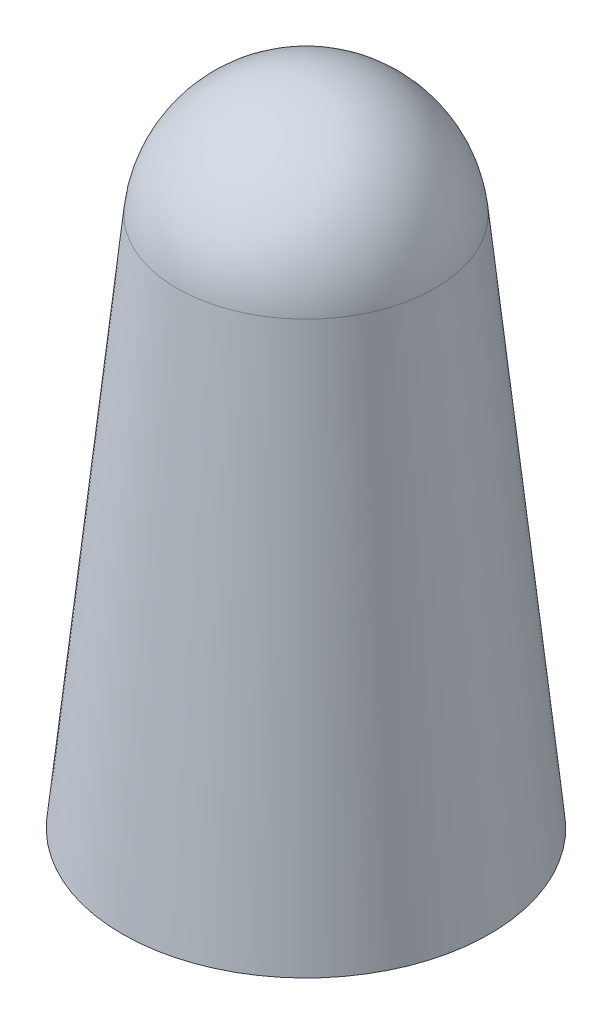
from build123d import *


with BuildPart() as part:
    # Esquisse1 → Révolution1 (revolve)
    with BuildSketch(Plane.XY, mode=Mode.PRIVATE) as r_volution1_sk:
        with BuildLine():
            Line((-2.5, 0), (-4.25, 0))
            Line((-4.25, 0), (-2.984258228, 12.306924789))
            ThreePointArc((-2.984258228, 12.306924789), (-2.009878806, 14.227192669), (0, 15))
            Line((0, 15), (0, 14))
            ThreePointArc((0, 14), (-1.414213562, 13.414213562), (-2, 12))
            Line((-2, 12), (-2, 6))
            Line((-2, 6), (-2.5, 6))
            Line((-2.5, 6), (-2.5, 0))
        make_face()
    revolve(r_volution1_sk.sketch.rotate(Axis((0, 0, 0), (0, 1, 0)), 270), axis=Axis((0, 0, 0), (0, 1, 0)))  # turned: the seam where the file's is


solid = part.part
